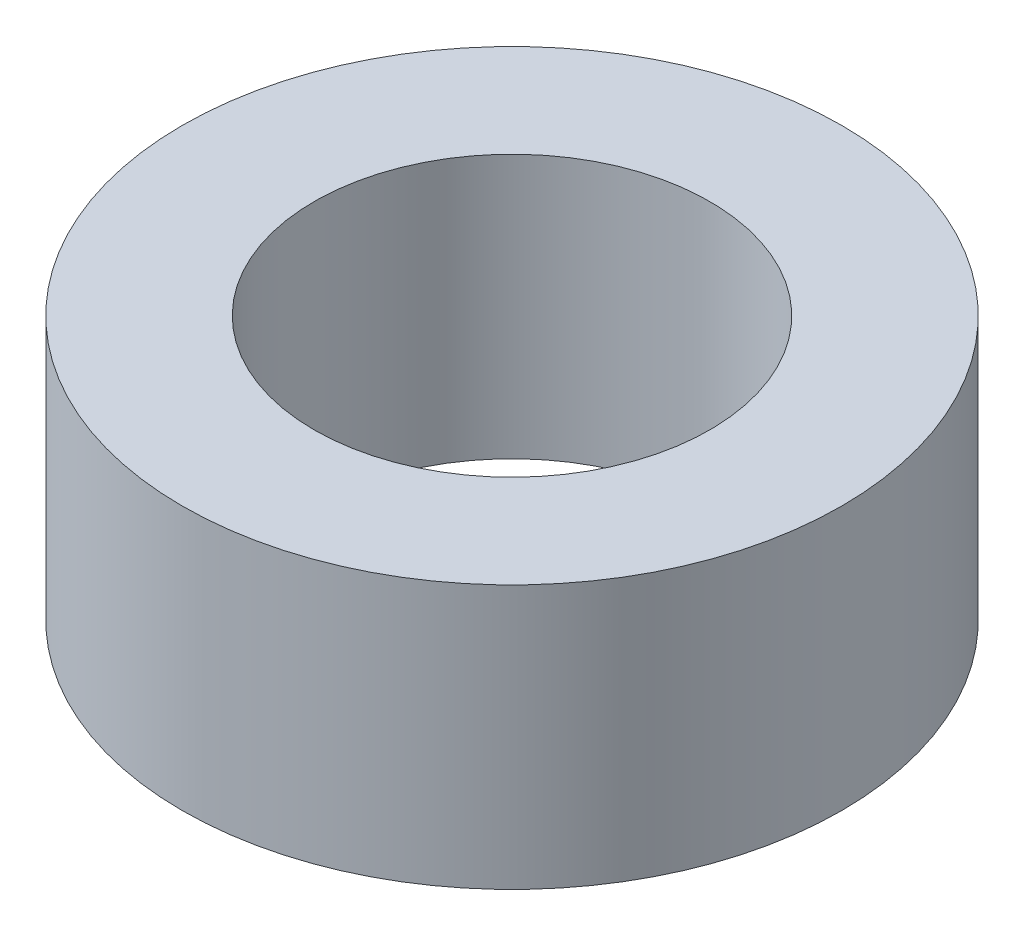
from build123d import *

# Parameters (mm, degrees)
SKETCH1_R           = 7.9375
BOSS_EXTRUDE1_DEPTH = 6.35
SKETCH2_R           = 4.7625
CUT_EXTRUDE1_DEPTH  = 7.35


with BuildPart() as part:
    # Sketch1 → Boss-Extrude1 (new body)
    with BuildSketch(Plane(origin=(0, 0, 0), x_dir=(1, 0, 0), z_dir=(0, 1, 0))):
        Circle(SKETCH1_R)
    extrude(amount=BOSS_EXTRUDE1_DEPTH)

    # Sketch2 → Cut-Extrude1 (cut, through all)
    with BuildSketch(Plane(origin=(0, 6.35, 0), x_dir=(1, 0, 0), z_dir=(0, 1, 0))):
        Circle(SKETCH2_R)
    extrude(amount=-CUT_EXTRUDE1_DEPTH, mode=Mode.SUBTRACT)


solid = part.part
